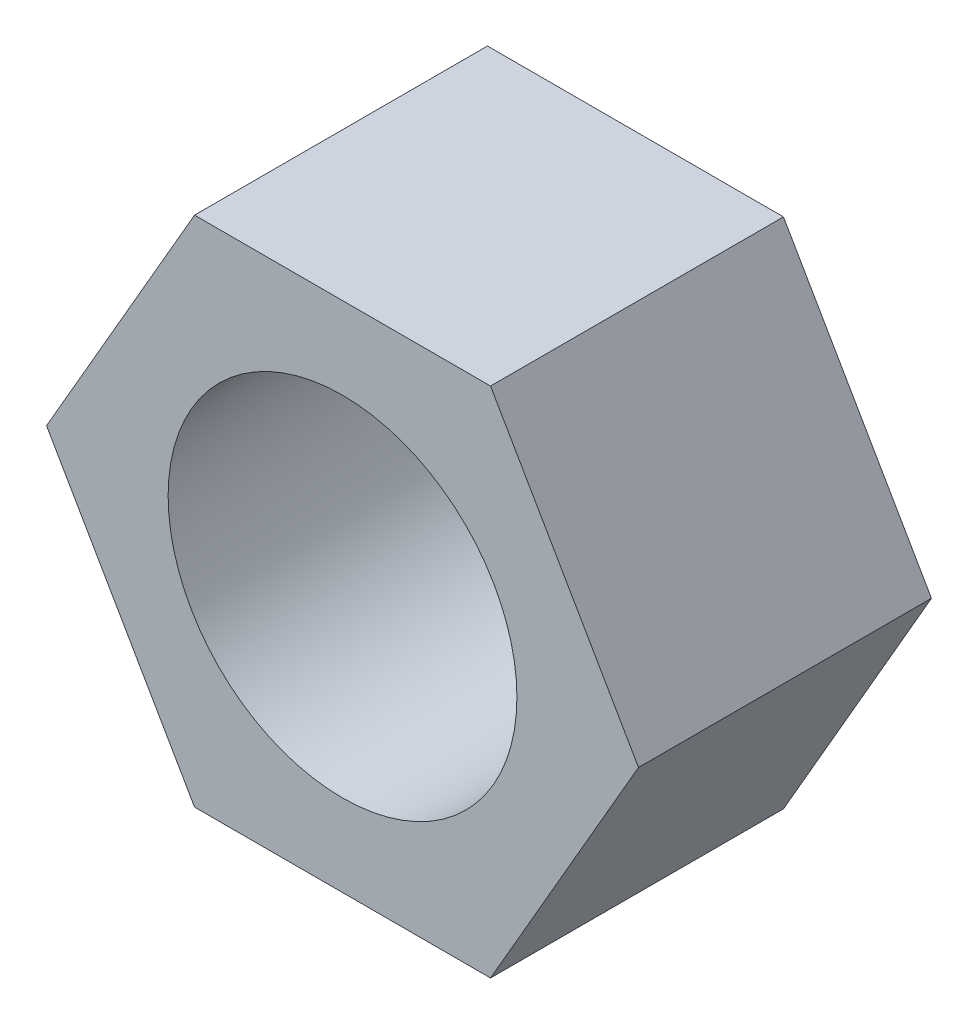
from build123d import *

# Parameters (mm, degrees)
BOSS_EXTRUDE1_DEPTH = 8
SKETCH2_R           = 4.7625
CUT_EXTRUDE1_DEPTH  = 8


with BuildPart() as part:
    # Sketch1 → Boss-Extrude1 (new body)
    with BuildSketch(Plane.XY):
        Polygon((8.082903769, 0), (4.041451884, 7), (-4.041451884, 7), (-8.082903769, 0), (-4.041451884, -7), (4.041451884, -7), align=None)
    extrude(amount=BOSS_EXTRUDE1_DEPTH)

    # Sketch2 → Cut-Extrude1 (cut)
    with BuildSketch(Plane(origin=(0, 0, 0), x_dir=(-1, 0, 0), z_dir=(0, 0, -1))):
        Circle(SKETCH2_R)
    extrude(amount=-CUT_EXTRUDE1_DEPTH, mode=Mode.SUBTRACT)


solid = part.part
